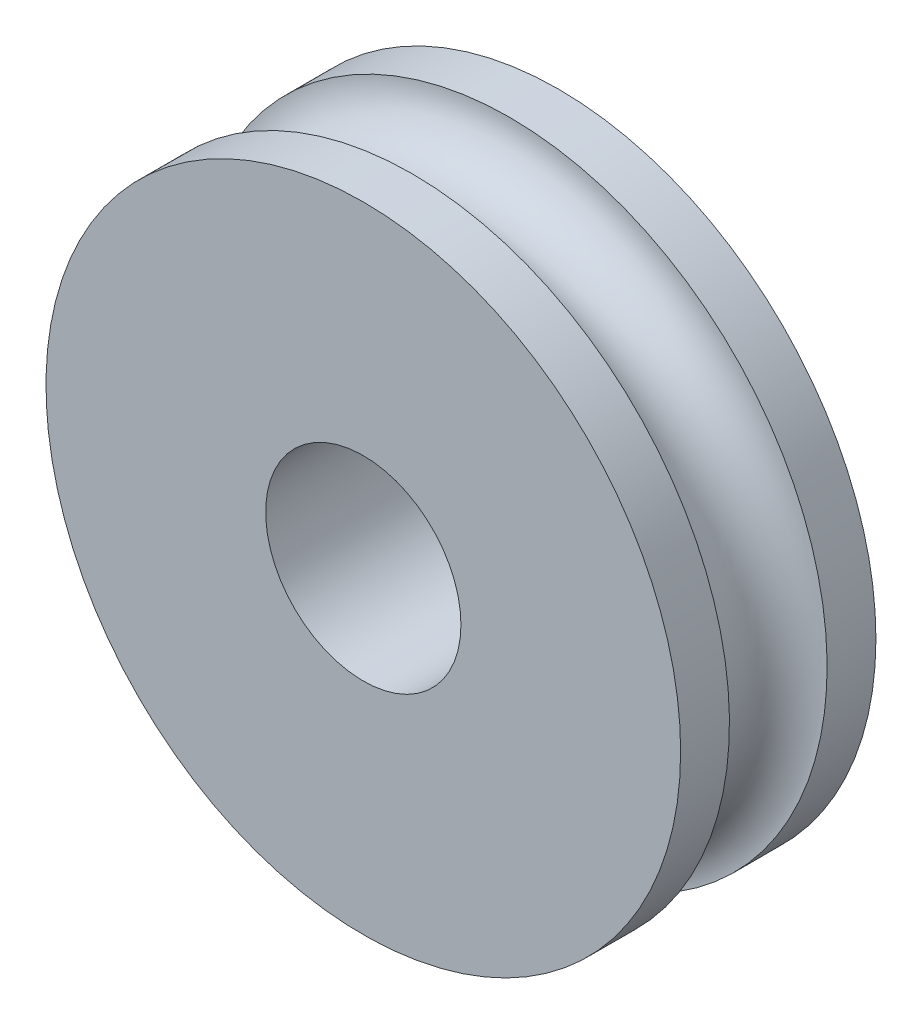
from build123d import *

# Parameters (mm, degrees)
SKETCH1_R           = 6.5
BOSS_EXTRUDE1_DEPTH = 4
SKETCH2_R           = 2
CUT_EXTRUDE1_DEPTH  = 5
SKETCH4_R           = 1


with BuildPart() as part:
    # Sketch1 → Boss-Extrude1 (new body)
    with BuildSketch(Plane.XY):
        Circle(SKETCH1_R)
    extrude(amount=BOSS_EXTRUDE1_DEPTH)

    # Sketch2 → Cut-Extrude1 (cut, through all)
    with BuildSketch(Plane.XY.offset(4)):
        Circle(SKETCH2_R)
    extrude(amount=-CUT_EXTRUDE1_DEPTH, mode=Mode.SUBTRACT)

    # Cut-Sweep1: sweep along a path in Sketch3
    with BuildLine(Plane.XY.offset(2)) as cut_sweep1_path:
        CenterArc((0, 0), 6.5, 0, 360)
    # Sketch4 → Cut-Sweep1 (sweep, cut)
    with BuildSketch(Plane(origin=(0, 0, 0), x_dir=(0, 0, -1), z_dir=(1, 0, 0))):
        with Locations((-2, 6.5)):
            Circle(SKETCH4_R)
    sweep(path=cut_sweep1_path.line, mode=Mode.SUBTRACT)


solid = part.part
